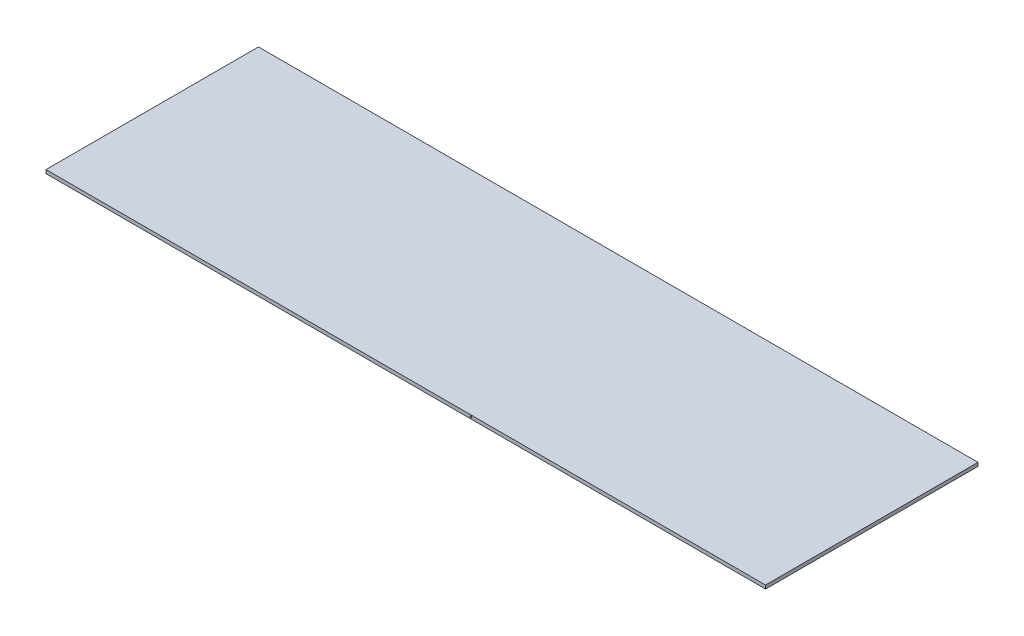
from build123d import *

# Parameters (mm, degrees)
SKETCH1_W           = 1016
SKETCH1_H           = 300
BOSS_EXTRUDE1_DEPTH = 5
SKETCH2_R           = 1.25
CUT_EXTRUDE1_DEPTH  = 301


with BuildPart() as part:
    # Sketch1 → Boss-Extrude1 (new body)
    with BuildSketch(Plane(origin=(0, 0, 0), x_dir=(1, 0, 0), z_dir=(0, 1, 0))):
        with Locations((508, 150)):
            Rectangle(SKETCH1_W, SKETCH1_H)
    extrude(amount=BOSS_EXTRUDE1_DEPTH)

    # Sketch2 → Cut-Extrude1 (cut, through all)
    with BuildSketch(Plane.XY):
        with Locations((600, 2.576267447)):
            Circle(SKETCH2_R)
    extrude(amount=-CUT_EXTRUDE1_DEPTH, mode=Mode.SUBTRACT)


solid = part.part
